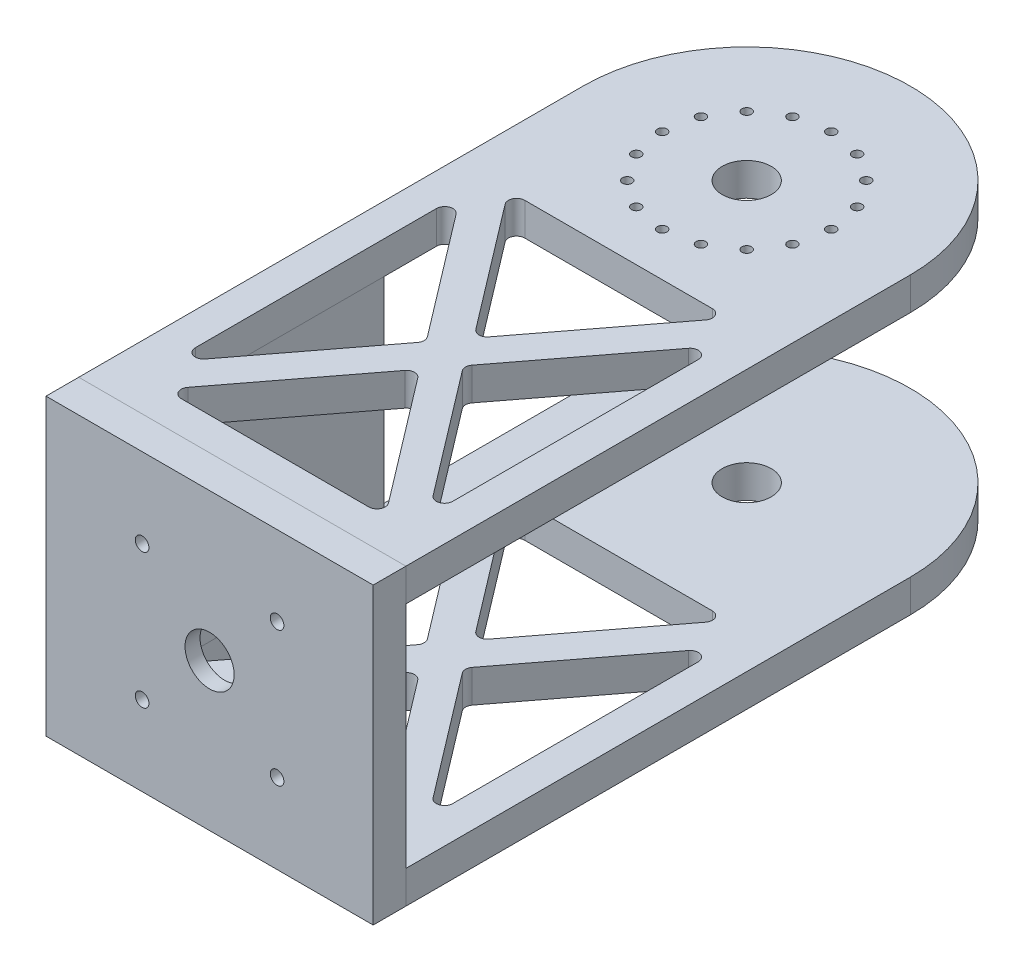
from build123d import *

# Parameters (mm, degrees)
SKETCH1_R               = 9
BOSS_EXTRUDE1_DEPTH     = 12
SKETCH2_R               = 1.75
CUT_EXTRUDE1_DEPTH      = 12
SKETCH3_W               = 12
SKETCH3_H               = 100
SS_DEPTH                = 84
BOSS_EXTRUDE3_START     = -84
SKETCH1_3_R             = 9
BOSS_EXTRUDE3_DEPTH     = 12
SKETCH4_W               = 120
SKETCH4_H               = 108
BOSS_EXTRUDE4_DEPTH     = 12
SKETCH5_R               = 9
SKETCH5_R_2             = 2.5
CUT_EXTRUDE2_DEPTH      = 246
CUT_EXTRUDE2_DEPTH_BACK = 13
SKETCH5_3_W             = 70
SKETCH5_3_H             = 70
CUT_EXTRUDE3_DEPTH      = 3
CUT_EXTRUDE4_START      = -3
SKETCH5_4_R             = 25
CUT_EXTRUDE4_DEPTH      = 3.5
FILLET1_R               = 6
CUT_EXTRUDE5_DEPTH      = 1
CUT_EXTRUDE5_DEPTH_BACK = 109


with BuildPart() as part:
    # Sketch1 → Boss-Extrude1 (new body)
    with BuildSketch(Plane(origin=(0, 0, 0), x_dir=(-1, 0, 0), z_dir=(0, 1, 0))):
        with BuildLine():
            Line((-60, 0), (-60, 185))
            Line((-60, 185), (60, 185))
            Line((60, 185), (60, 0))
            ThreePointArc((60, 0), (0, -60), (-60, 0))
        make_face()
        Circle(SKETCH1_R, mode=Mode.SUBTRACT)
    extrude(amount=BOSS_EXTRUDE1_DEPTH)

    # Sketch2 → Cut-Extrude1 (cut)
    with BuildSketch(Plane.XZ):
        with Locations((0, 31)):
            Circle(SKETCH2_R)
        with Locations((11.863186403, 28.640265508)):
            Circle(SKETCH2_R)
        with Locations((21.920310217, 21.920310217)):
            Circle(SKETCH2_R)
        with Locations((28.640265508, 11.863186403)):
            Circle(SKETCH2_R)
        with Locations((31, 0)):
            Circle(SKETCH2_R)
        with Locations((28.640265508, -11.863186403)):
            Circle(SKETCH2_R)
        with Locations((21.920310217, -21.920310217)):
            Circle(SKETCH2_R)
        with Locations((11.863186403, -28.640265508)):
            Circle(SKETCH2_R)
        with Locations((0, -31)):
            Circle(SKETCH2_R)
        with Locations((-11.863186403, -28.640265508)):
            Circle(SKETCH2_R)
        with Locations((-21.920310217, -21.920310217)):
            Circle(SKETCH2_R)
        with Locations((-28.640265508, -11.863186403)):
            Circle(SKETCH2_R)
        with Locations((-31, 0)):
            Circle(SKETCH2_R)
        with Locations((-28.640265508, 11.863186403)):
            Circle(SKETCH2_R)
        with Locations((-21.920310217, 21.920310217)):
            Circle(SKETCH2_R)
        with Locations((-11.863186403, 28.640265508)):
            Circle(SKETCH2_R)
    extrude(amount=-CUT_EXTRUDE1_DEPTH, mode=Mode.SUBTRACT)


with BuildPart() as body_2:
    # Sketch3 → ss (new body)
    with BuildSketch(Plane.XZ):
        with Locations((-54, 135)):
            Rectangle(SKETCH3_W, SKETCH3_H)
    extrude(amount=SS_DEPTH)


with BuildPart() as body_3:
    # Sketch1_3 → Boss-Extrude3 (new body)
    with BuildSketch(Plane(origin=(0, 0, 0), x_dir=(-1, 0, 0), z_dir=(0, 1, 0)).offset(BOSS_EXTRUDE3_START)):
        with BuildLine():
            Line((-60, 0), (-60, 185))
            Line((-60, 185), (60, 185))
            Line((60, 185), (60, 0))
            ThreePointArc((60, 0), (0, -60), (-60, 0))
        make_face()
        Circle(SKETCH1_3_R, mode=Mode.SUBTRACT)
    extrude(amount=-BOSS_EXTRUDE3_DEPTH)


with BuildPart() as body_4:
    # Sketch4 → Boss-Extrude4 (new body)
    with BuildSketch(Plane.XY.offset(185)):
        with Locations((0, -42)):
            Rectangle(SKETCH4_W, SKETCH4_H)
    extrude(amount=BOSS_EXTRUDE4_DEPTH)

    # Sketch5 → Cut-Extrude2 (cut, two sides)
    with BuildSketch(Plane(origin=(0, 0, 185), x_dir=(1, 0, 0), z_dir=(0, 0, -1))) as cut_extrude2_sk:
        with Locations((0, 42)):
            Circle(SKETCH5_R)
        with Locations((-24.748737342, 66.748737342)):
            Circle(SKETCH5_R_2)
        with Locations((24.748737342, 66.748737342)):
            Circle(SKETCH5_R_2)
        with Locations((24.748737342, 17.251262658)):
            Circle(SKETCH5_R_2)
        with Locations((-24.748737342, 17.251262658)):
            Circle(SKETCH5_R_2)
    extrude(amount=CUT_EXTRUDE2_DEPTH, mode=Mode.SUBTRACT)
    extrude(cut_extrude2_sk.sketch, amount=-CUT_EXTRUDE2_DEPTH_BACK, mode=Mode.SUBTRACT)

    # Sketch5_3 → Cut-Extrude3 (cut)
    with BuildSketch(Plane(origin=(0, 0, 185), x_dir=(1, 0, 0), z_dir=(0, 0, -1))):
        with Locations((0, 42)):
            Rectangle(SKETCH5_3_W, SKETCH5_3_H)
    extrude(amount=-CUT_EXTRUDE3_DEPTH, mode=Mode.SUBTRACT)

    # Sketch5_4 → Cut-Extrude4 (cut)
    with BuildSketch(Plane(origin=(0, 0, 185), x_dir=(1, 0, 0), z_dir=(0, 0, -1)).offset(CUT_EXTRUDE4_START)):
        with Locations((0, 42)):
            Circle(SKETCH5_4_R)
    extrude(amount=-CUT_EXTRUDE4_DEPTH, mode=Mode.SUBTRACT)

    # Fillet1
    fillet1_edges = [body_4.edges().sort_by_distance(p)[0] for p in [
        (-35, -7, 186.5),
        (-35, -77, 186.5),
        (35, -77, 186.5),
        (35, -7, 186.5),
    ]]
    fillet(fillet1_edges, radius=FILLET1_R)


with BuildPart() as cut_extrude5_tool:
    # Sketch6 → Cut-Extrude5 (new body, two sides)
    with BuildSketch(Plane(origin=(0, 12, 0), x_dir=(1, 0, 0), z_dir=(0, 1, 0))) as cut_extrude5_sk:
        with BuildLine():
            Line((36.785970489, -168.181870354), (2.38629516, -123.032296484))
            ThreePointArc((2.38629516, -123.032296484), (0, -121.85042613), (-2.38629516, -123.032296484))
            Line((-2.38629516, -123.032296484), (-36.785970489, -168.181870354))
            ThreePointArc((-36.785970489, -168.181870354), (-37.088019517, -171.331467435), (-34.399675329, -173))
            Line((-34.399675329, -173), (34.399675329, -173))
            ThreePointArc((34.399675329, -173), (37.088019517, -171.331467435), (36.785970489, -168.181870354))
        make_face()
        with BuildLine():
            Line((34.399675329, -47), (-34.399675329, -47))
            ThreePointArc((-34.399675329, -47), (-37.088019517, -48.668532565), (-36.785970489, -51.818129646))
            Line((-36.785970489, -51.818129646), (-2.38629516, -96.967703516))
            ThreePointArc((-2.38629516, -96.967703516), (0, -98.14957387), (2.38629516, -96.967703516))
            Line((2.38629516, -96.967703516), (36.785970489, -51.818129646))
            ThreePointArc((36.785970489, -51.818129646), (37.088019517, -48.668532565), (34.399675329, -47))
        make_face()
        with BuildLine():
            Line((48, -65.78792613), (48, -155.829108344))
            ThreePointArc((48, -155.829108344), (45.959456752, -158.671544402), (42.61370484, -157.64723799))
            Line((42.61370484, -157.64723799), (8.312302092, -112.626646883))
            ThreePointArc((8.312302092, -112.626646883), (7.698597252, -110.808517237), (8.312302092, -108.990387591))
            Line((8.312302092, -108.990387591), (42.61370484, -63.969796484))
            ThreePointArc((42.61370484, -63.969796484), (45.959456752, -62.945490073), (48, -65.78792613))
        make_face()
        with BuildLine():
            Line((-48, -65.78792613), (-48, -154.21207387))
            ThreePointArc((-48, -154.21207387), (-45.959456752, -157.054509927), (-42.61370484, -156.030203516))
            Line((-42.61370484, -156.030203516), (-8.928315225, -111.818129646))
            ThreePointArc((-8.928315225, -111.818129646), (-8.314610385, -110), (-8.928315225, -108.181870354))
            Line((-8.928315225, -108.181870354), (-42.61370484, -63.969796484))
            ThreePointArc((-42.61370484, -63.969796484), (-45.959456752, -62.945490073), (-48, -65.78792613))
        make_face()
    extrude(amount=CUT_EXTRUDE5_DEPTH)
    extrude(cut_extrude5_sk.sketch, amount=-CUT_EXTRUDE5_DEPTH_BACK)


with BuildPart() as part_1:
    add(part.part)

    # Cut-Extrude5: cut by cut_extrude5_tool
    add(cut_extrude5_tool.part, mode=Mode.SUBTRACT)


with BuildPart() as body_3_1:
    add(body_3.part)

    # Cut-Extrude5: cut by cut_extrude5_tool
    add(cut_extrude5_tool.part, mode=Mode.SUBTRACT)


solid = Compound([body_2.part, body_4.part, part_1.part, body_3_1.part])
